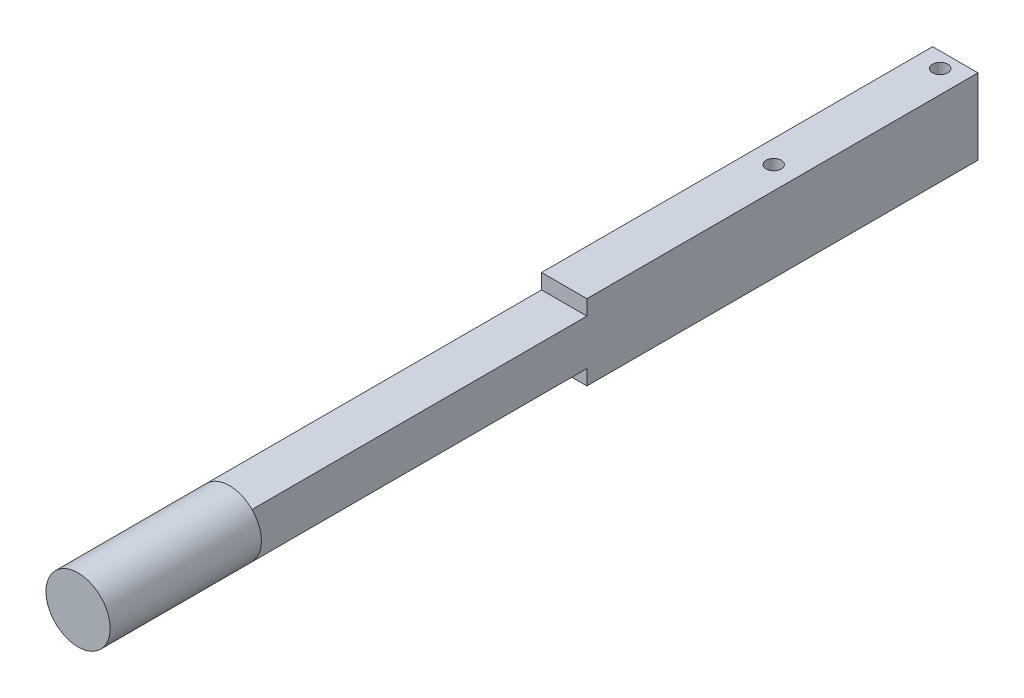
from build123d import *

# Parameters (mm, degrees)
SKETCH2_W           = 38.1
SKETCH2_H           = 38.1
BOSS_EXTRUDE1_DEPTH = 609.6
SKETCH3_R           = 26.940768363
BOSS_EXTRUDE2_DEPTH = 127
CUT_EXTRUDE2_DEPTH  = 127
BOSS_EXTRUDE3_DEPTH = 38.1
SKETCH6_R           = 6.35
CUT_EXTRUDE4_DEPTH  = 64.5
SKETCH7_R           = 6.35
CUT_EXTRUDE5_DEPTH  = 533.4


with BuildPart() as part:
    # Sketch2 → Boss-Extrude1 (new body)
    with BuildSketch(Plane.XY):
        Rectangle(SKETCH2_W, SKETCH2_H)
    extrude(amount=BOSS_EXTRUDE1_DEPTH)

    # Sketch3 → Boss-Extrude2 (add)
    with BuildSketch(Plane.XY.offset(609.6)):
        Circle(SKETCH3_R)
    extrude(amount=BOSS_EXTRUDE2_DEPTH)

    # Sketch4 → Cut-Extrude2 (cut)
    with BuildSketch(Plane.XZ.offset(19.05)):
        with BuildLine():
            ThreePointArc((-6.35, 152.4), (0, 146.05), (6.35, 152.4))
            Line((6.35, 152.4), (-6.35, 152.4))
        make_face()
        with BuildLine():
            Line((-6.35, 152.4), (6.35, 152.4))
            ThreePointArc((6.35, 152.4), (0, 158.75), (-6.35, 152.4))
        make_face()
    extrude(amount=-CUT_EXTRUDE2_DEPTH, mode=Mode.SUBTRACT)

    # Sketch5 → Boss-Extrude3 (add)
    with BuildSketch(Plane(origin=(19.05, 0, 0), x_dir=(0, 0, -1), z_dir=(1, 0, 0))):
        Polygon((0, 0), (0, 31.75), (-328.383343368, 31.75), (-328.383343368, -31.75), (0, -31.75), align=None)
    extrude(amount=-BOSS_EXTRUDE3_DEPTH)

    # Sketch6 → Cut-Extrude4 (cut, through all)
    with BuildSketch(Plane.XZ.offset(31.75)):
        with Locations((0, 152.494180782)):
            Circle(SKETCH6_R)
    extrude(amount=-CUT_EXTRUDE4_DEPTH, mode=Mode.SUBTRACT)

    # Sketch7 → Cut-Extrude5 (cut)
    with BuildSketch(Plane.XZ.offset(31.75)):
        with Locations((0, 12.7)):
            Circle(SKETCH7_R)
    extrude(amount=-CUT_EXTRUDE5_DEPTH, mode=Mode.SUBTRACT)


solid = part.part
